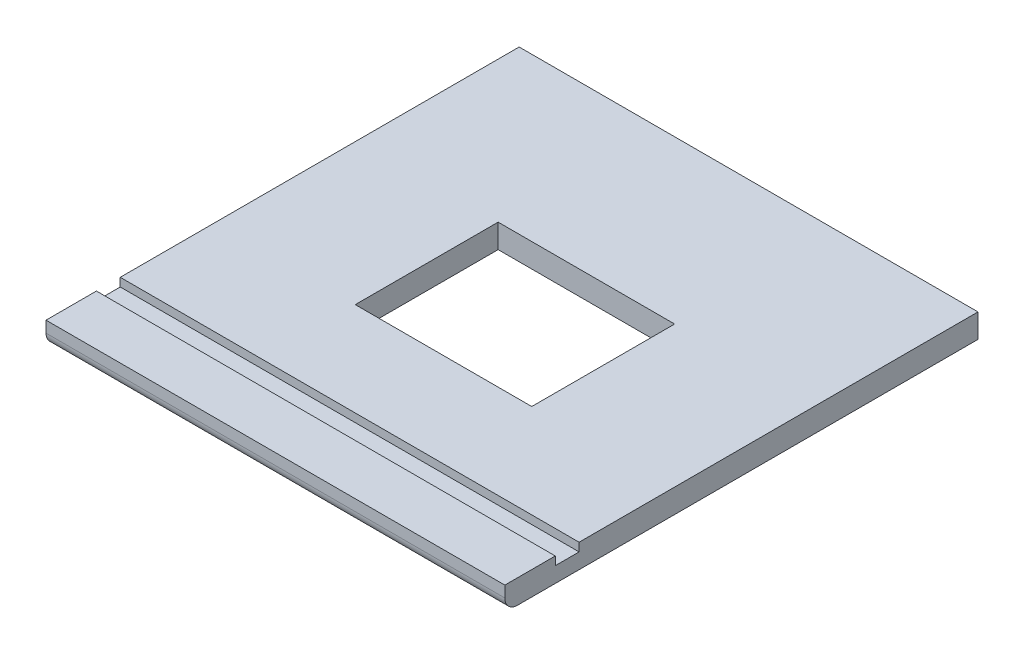
from build123d import *

# Parameters (mm, degrees)
SKETCH1_W           = 346.7
SKETCH1_H           = 357.50000001
BOSS_EXTRUDE1_DEPTH = 18
SKETCH2_W           = 346.7
SKETCH2_H           = 18
CUT_EXTRUDE1_DEPTH  = 6.35
SKETCH3_W           = 133.35
SKETCH3_H           = 107.95
CUT_EXTRUDE3_DEPTH  = 19
FILLET1_R           = 9.525


with BuildPart() as part:
    # Sketch1 → Boss-Extrude1 (new body)
    with BuildSketch(Plane(origin=(0, 0, 0), x_dir=(1, 0, 0), z_dir=(0, 1, 0))):
        with Locations((173.35, -178.750000005)):
            Rectangle(SKETCH1_W, SKETCH1_H)
    extrude(amount=BOSS_EXTRUDE1_DEPTH)

    # Sketch2 → Cut-Extrude1 (cut)
    with BuildSketch(Plane(origin=(0, 18, 0), x_dir=(1, 0, 0), z_dir=(0, 1, 0))):
        with Locations((173.35, -310.40000001)):
            Rectangle(SKETCH2_W, SKETCH2_H)
    extrude(amount=-CUT_EXTRUDE1_DEPTH, mode=Mode.SUBTRACT)

    # Sketch3 → Cut-Extrude3 (cut, through all)
    with BuildSketch(Plane(origin=(0, 18, 0), x_dir=(1, 0, 0), z_dir=(0, 1, 0))):
        with Locations((173.35, -176.52500001)):
            Rectangle(SKETCH3_W, SKETCH3_H)
    extrude(amount=-CUT_EXTRUDE3_DEPTH, mode=Mode.SUBTRACT)

    # Fillet1
    fillet1_edges = [part.edges().sort_by_distance(p)[0] for p in [
        (173.35, 0, 357.50000001),
    ]]
    fillet(fillet1_edges, radius=FILLET1_R)


solid = part.part
